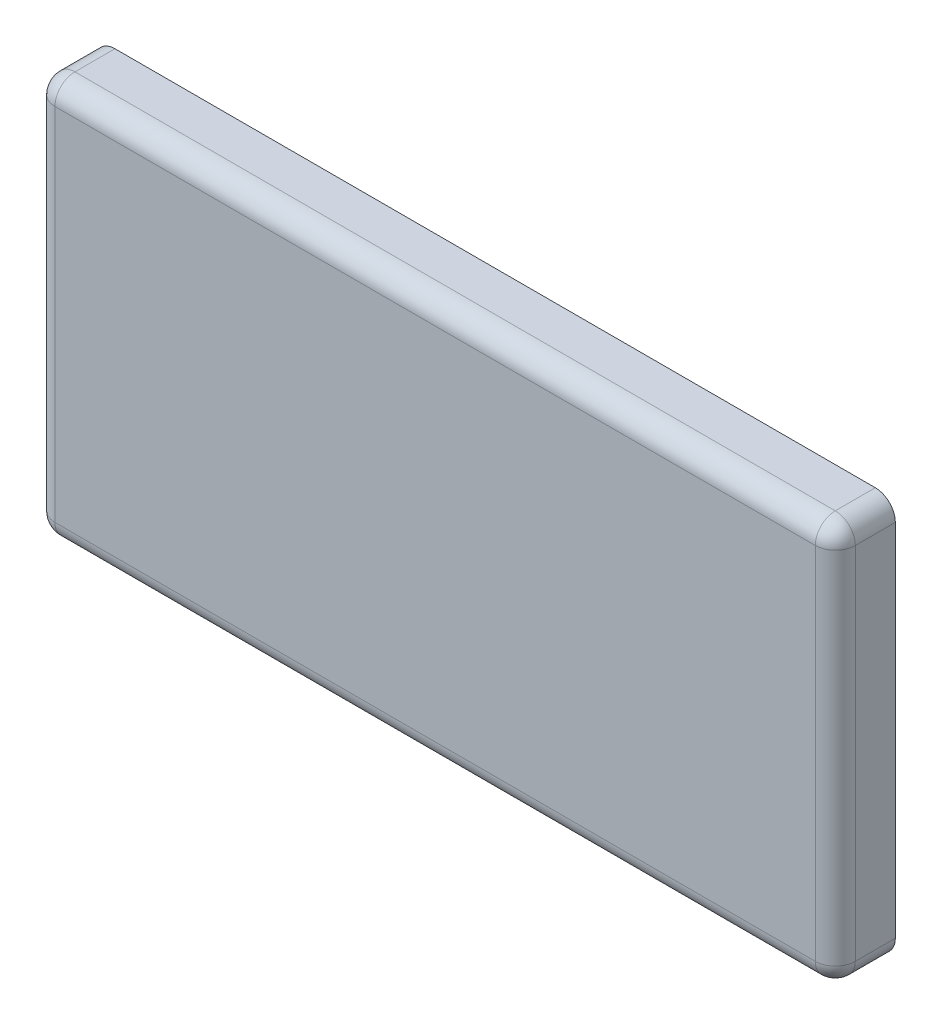
from build123d import *

# Parameters (mm, degrees)
SKETCH1_W           = 200
SKETCH1_H           = 100
BOSS_EXTRUDE1_DEPTH = 15
FILLET1_R           = 5


with BuildPart() as part:
    # Sketch1 → Boss-Extrude1 (new body)
    with BuildSketch(Plane.XY):
        Rectangle(SKETCH1_W, SKETCH1_H)
    extrude(amount=BOSS_EXTRUDE1_DEPTH)

    # Fillet1
    fillet1_edges = [part.edges().sort_by_distance(p)[0] for p in [
        (100, 0, 15),
        (0, 50, 15),
        (-100, 0, 15),
        (-100, 50, 7.5),
        (100, 50, 7.5),
        (100, -50, 7.5),
        (-100, -50, 7.5),
        (0, -50, 15),
    ]]
    fillet(fillet1_edges, radius=FILLET1_R)


solid = part.part
